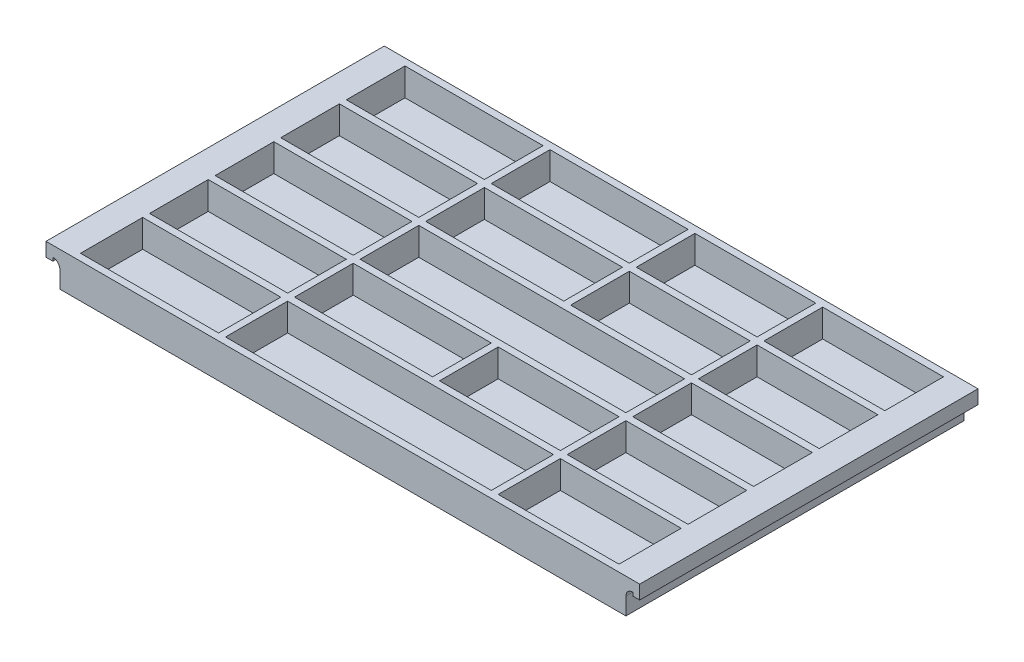
from build123d import *

# Parameters (mm, degrees)
SKETCH1_W    = 203.2
SKETCH1_H    = 124.46
SKETCH1_W_2  = 44.45
SKETCH1_H_2  = 22.86
SKETCH1_H_3  = 21.59
SKETCH1_W_3  = 50.8
SKETCH1_W_4  = 97.79
TRAY_DEPTH   = 10.16
SKETCH3_W    = 203.2
SKETCH3_H    = 124.46
BASE_DEPTH   = 2.54
HANDLE_DEPTH = 124.46


with BuildPart() as part:
    # Sketch1 → tray (new body)
    with BuildSketch(Plane(origin=(0, 0, 0), x_dir=(1, 0, 0), z_dir=(0, 1, 0))):
        Rectangle(SKETCH1_W, SKETCH1_H)
        with Locations((76.835, -48.26)):
            Rectangle(SKETCH1_W_2, SKETCH1_H_2, mode=Mode.SUBTRACT)
        with Locations((76.835, 48.895)):
            Rectangle(SKETCH1_W_2, SKETCH1_H_3, mode=Mode.SUBTRACT)
        with Locations((-73.66, -48.26)):
            Rectangle(SKETCH1_W_3, SKETCH1_H_2, mode=Mode.SUBTRACT)
        with Locations((-73.66, 48.895)):
            Rectangle(SKETCH1_W_3, SKETCH1_H_3, mode=Mode.SUBTRACT)
        with Locations((-73.66, 24.765)):
            Rectangle(SKETCH1_W_3, SKETCH1_H_3, mode=Mode.SUBTRACT)
        with Locations((-73.66, 0.635)):
            Rectangle(SKETCH1_W_3, SKETCH1_H_3, mode=Mode.SUBTRACT)
        with Locations((-73.66, -23.495)):
            Rectangle(SKETCH1_W_3, SKETCH1_H_3, mode=Mode.SUBTRACT)
        with Locations((-20.32, 48.895)):
            Rectangle(SKETCH1_W_3, SKETCH1_H_3, mode=Mode.SUBTRACT)
        with Locations((29.845, 48.895)):
            Rectangle(SKETCH1_W_2, SKETCH1_H_3, mode=Mode.SUBTRACT)
        with Locations((-20.32, -23.495)):
            Rectangle(SKETCH1_W_3, SKETCH1_H_3, mode=Mode.SUBTRACT)
        with Locations((29.845, -23.495)):
            Rectangle(SKETCH1_W_2, SKETCH1_H_3, mode=Mode.SUBTRACT)
        with Locations((29.845, 24.765)):
            Rectangle(SKETCH1_W_2, SKETCH1_H_3, mode=Mode.SUBTRACT)
        with Locations((-20.32, 24.765)):
            Rectangle(SKETCH1_W_3, SKETCH1_H_3, mode=Mode.SUBTRACT)
        with Locations((3.175, 0.635)):
            Rectangle(SKETCH1_W_4, SKETCH1_H_3, mode=Mode.SUBTRACT)
        with Locations((3.175, -48.26)):
            Rectangle(SKETCH1_W_4, SKETCH1_H_2, mode=Mode.SUBTRACT)
        with Locations((76.835, -23.495)):
            Rectangle(SKETCH1_W_2, SKETCH1_H_3, mode=Mode.SUBTRACT)
        with Locations((76.835, 0.635)):
            Rectangle(SKETCH1_W_2, SKETCH1_H_3, mode=Mode.SUBTRACT)
        with Locations((76.835, 24.765)):
            Rectangle(SKETCH1_W_2, SKETCH1_H_3, mode=Mode.SUBTRACT)
    extrude(amount=TRAY_DEPTH)

    # Sketch3 → base (add)
    with BuildSketch(Plane(origin=(0, 0, 0), x_dir=(-1, 0, 0), z_dir=(0, -1, 0))):
        Rectangle(SKETCH3_W, SKETCH3_H)
    extrude(amount=BASE_DEPTH)

    # Sketch4 → handle (add)
    with BuildSketch(Plane.XY.offset(62.23)):
        with BuildLine():
            Line((-101.6, -2.54), (-101.6, 10.16))
            Line((-101.6, 10.16), (-109.22, 10.16))
            Line((-109.22, 10.16), (-109.22, 5.08))
            Line((-109.22, 5.08), (-106.68, 5.08))
            Line((-106.68, 5.08), (-106.68, 6.35))
            ThreePointArc((-106.68, 6.35), (-104.883948776, 5.606051224), (-104.14, 3.81))
            Line((-104.14, 3.81), (-104.14, -2.54))
            Line((-104.14, -2.54), (-101.6, -2.54))
        make_face()
        with BuildLine():
            Line((101.6, -2.54), (104.14, -2.54))
            Line((104.14, -2.54), (104.14, 3.81))
            ThreePointArc((104.14, 3.81), (104.883948776, 5.606051224), (106.68, 6.35))
            Line((106.68, 6.35), (106.68, 5.08))
            Line((106.68, 5.08), (109.22, 5.08))
            Line((109.22, 5.08), (109.22, 10.16))
            Line((109.22, 10.16), (101.6, 10.16))
            Line((101.6, 10.16), (101.6, -2.54))
        make_face()
    extrude(amount=-HANDLE_DEPTH)


solid = part.part
